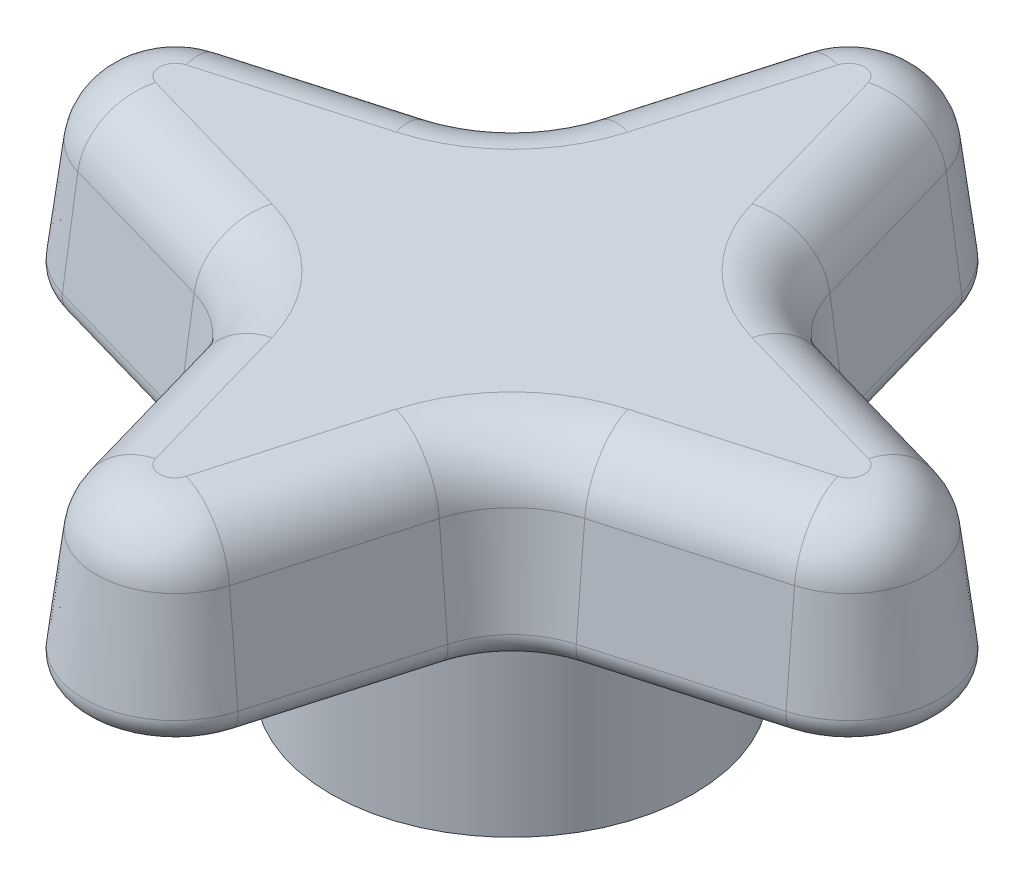
from build123d import *

# Parameters (mm, degrees)
EXTRUDE1_DEPTH = 6.35
EXTRUDE1_TAPER = 7.000000000000015
FILLET1_R      = 2.2224999999999997
SKETCH2_R      = 6.35
SKETCH2_R_2    = 4.7625
EXTRUDE2_DEPTH = 6.35
FILLET2_R      = 0.762


with BuildPart() as part:
    # Sketch1 → Extrude1 (new body)
    with BuildSketch(Plane(origin=(0, 0, 0), x_dir=(1, 0, 0), z_dir=(0, 1, 0))):
        with BuildLine():
            ThreePointArc((3.174999999999997, 12.7), (2.4e-15, 15.092534109076349), (-3.17499999999998, 12.7))
            Line((-3.17499999999998, 12.7), (-4.812500349494196, 6.989357629379411))
            ThreePointArc((-4.812500349494196, 6.989357629379411), (-5.619442203831074, 5.619442203831092), (-6.989357629379396, 4.812500349494221))
            Line((-6.989357629379396, 4.812500349494221), (-12.699999999999969, 3.1750000000000442))
            ThreePointArc((-12.699999999999969, 3.1750000000000442), (-15.092534109076396, -4e-16), (-12.699999999999969, -3.1750000000000442))
            Line((-12.699999999999969, -3.1750000000000442), (-6.989357629379396, -4.812500349494221))
            ThreePointArc((-6.989357629379396, -4.812500349494221), (-5.619442203831074, -5.619442203831092), (-4.812500349494196, -6.989357629379411))
            Line((-4.812500349494196, -6.989357629379411), (-3.17499999999998, -12.7))
            ThreePointArc((-3.17499999999998, -12.7), (3.14e-15, -15.092534109076366), (3.174999999999997, -12.7))
            Line((3.174999999999997, -12.7), (4.812500349494196, -6.989357629379411))
            ThreePointArc((4.812500349494196, -6.989357629379411), (5.619442203831074, -5.619442203831092), (6.989357629379396, -4.812500349494221))
            Line((6.989357629379396, -4.812500349494221), (12.699999999999985, -3.1750000000000442))
            ThreePointArc((12.699999999999985, -3.1750000000000442), (15.0925341090764, 0), (12.699999999999985, 3.1750000000000442))
            Line((12.699999999999985, 3.1750000000000442), (6.989357629379396, 4.812500349494221))
            ThreePointArc((6.989357629379396, 4.812500349494221), (5.619442203831074, 5.619442203831092), (4.812500349494196, 6.989357629379411))
            Line((4.812500349494196, 6.989357629379411), (3.174999999999997, 12.7))
        make_face()
    extrude(amount=EXTRUDE1_DEPTH, taper=EXTRUDE1_TAPER)

    # Fillet1
    fillet1_edges = [part.edges().sort_by_distance(p)[0] for p in [
        (3.2442717699186887, 6.35, 9.629769340379289),
        (5.068123801520522, 6.35, 5.068123801520543),
        (9.629769340379273, 6.35, 3.244271769918725),
        (14.312852147342955, 6.35, 1.33e-15),
        (9.629769340379273, 6.35, -3.2442717699187247),
        (5.068123801520526, 6.35, -5.06812380152054),
        (3.2442717699186923, 6.35, -9.629769340379278),
        (1.443e-14, 6.35, -14.312852147342902),
        (-3.2442717699186843, 6.35, -9.629769340379275),
        (-5.068123801520527, 6.35, -5.068123801520538),
        (-9.629769340379273, 6.35, -3.244271769918723),
        (-14.31285214734295, 6.35, 2.2e-16),
        (-9.629769340379273, 6.35, 3.244271769918723),
        (-5.068123801520526, 6.35, 5.06812380152054),
        (-3.2442717699186803, 6.35, 9.629769340379287),
        (1.155e-14, 6.35, 14.312852147342921),
    ]]
    fillet(fillet1_edges, radius=FILLET1_R)

    # Sketch2 → Extrude2 (add)
    with BuildSketch(Plane.XZ):
        with Locations(Location((0, 0, 0), (0, 0, 270))):
            Circle(SKETCH2_R)
        with Locations(Location((0, 0, 0), (0, 0, 270))):
            Circle(SKETCH2_R_2, mode=Mode.SUBTRACT)
    extrude(amount=EXTRUDE2_DEPTH)

    # Fillet2
    fillet2_edges = [part.edges().sort_by_distance(p)[0] for p in [
        (3.9937501747470967, 0, 9.844678814689704),
        (5.619442203831073, 0, 5.619442203831092),
        (7.99e-15, 0, 15.092534109076366),
        (-3.993750174747088, 0, 9.844678814689704),
        (9.84467881468969, 0, 3.9937501747471327),
        (-5.619442203831074, 0, 5.619442203831092),
        (15.0925341090764, 0, 3.3e-16),
        (-9.844678814689683, 0, 3.9937501747471327),
        (9.84467881468969, 0, -3.9937501747471327),
        (-15.092534109076396, 0, -3.3e-16),
        (5.619442203831074, 0, -5.619442203831092),
        (-9.844678814689683, 0, -3.9937501747471327),
        (3.9937501747470967, 0, -9.844678814689704),
        (-5.619442203831073, 0, -5.619442203831092),
        (8.88e-15, 0, -15.092534109076349),
        (-3.9937501747470883, 0, -9.844678814689704),
    ]]
    fillet(fillet2_edges, radius=FILLET2_R)


solid = part.part
